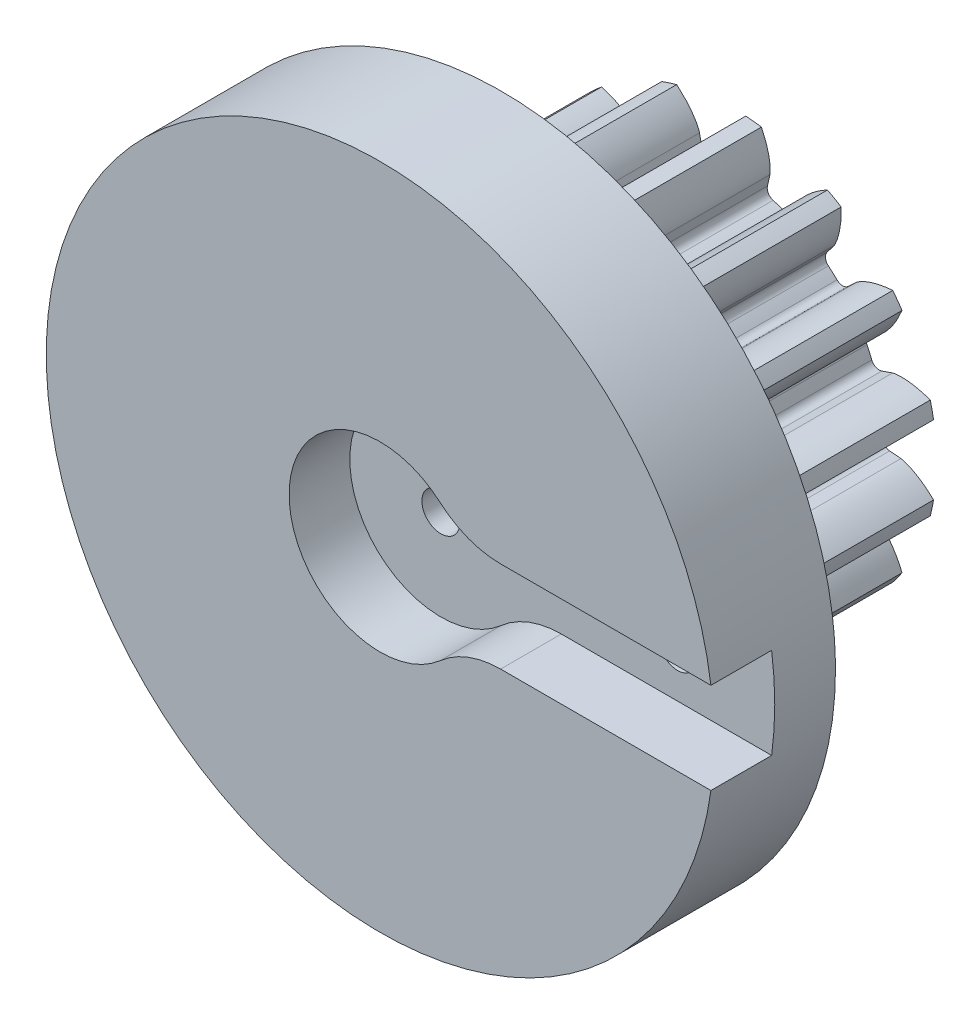
from build123d import *

# Parameters (mm, degrees)
SKETCH3_R                = 8.995833333
BOSS_EXTRUDE1_DEPTH      = 10.16
CUT_EXTRUDE1_DEPTH       = 17.281143532
FILLET1_R                = 0.355076163
CIRPATTERN1_COUNT        = 15
FILLET1_OF_CIRPATTERN1_R = 0.355076163
SCALE1_SCALE             = 1.9
SKETCH12_R               = 27.94
BOSS_EXTRUDE3_DEPTH      = 10.16
SKETCH13_R               = 5.08
CUT_EXTRUDE6_DEPTH       = 50.289093383
CUT_EXTRUDE7_DEPTH       = 5.08
SKETCH15_R               = 1.5875
CUT_EXTRUDE8_DEPTH       = 5.08
SKETCH16_R               = 2.74955
CUT_EXTRUDE9_DEPTH       = 3.81
SKETCH18_R               = 5.08
BOSS_EXTRUDE4_DEPTH      = 24.384
SKETCH19_R               = 2.794
CUT_EXTRUDE10_DEPTH      = 22.86
SKETCH20_R               = 1.5875
CUT_EXTRUDE11_DEPTH      = 46.649391906


with BuildPart() as part:
    # Sketch3 → Boss-Extrude1 (new body)
    with BuildSketch(Plane.XY):
        Circle(SKETCH3_R)
    extrude(amount=-BOSS_EXTRUDE1_DEPTH)

    # Sketch4 → Cut-Extrude1 (cut, symmetric)
    with BuildSketch(Plane.XY):
        with BuildLine():
            Line((6.587922, 0.593292844), (7.428746027, 0.669015489))
            add(Edge.make_bspline(
                [(7.428746027, 0.669015489), (7.431239529, 0.669275952), (7.438221543, 0.670116627), (7.45137303, 0.672140658), (7.47274968, 0.676058941), (7.499853291, 0.681954394), (7.534710401, 0.690607559), (7.575527841, 0.702125727), (7.620103171, 0.716165985), (7.668268726, 0.7329259), (7.716008275, 0.750953862), (7.763320815, 0.770148726), (7.810159557, 0.790358577), (7.866530888, 0.816118543), (7.933604431, 0.848781677), (8.011190656, 0.889523955), (8.098185635, 0.938742517), (8.185706836, 0.992089652), (8.27086582, 1.04719041), (8.355732614, 1.105822875), (8.437008174, 1.164648852), (8.520142822, 1.228735923), (8.59623198, 1.289414256), (8.679980615, 1.360650951), (8.747135157, 1.419094683), (8.815206291, 1.48214701), (8.84814287, 1.513228673), (8.864892817, 1.529278494)],
                knots=[0, 0, 0, 0, 0, 0.005376749, 0.015083688, 0.02853182, 0.04661014, 0.064854849, 0.092110525, 0.119476176, 0.146842496, 0.174208854, 0.201574956, 0.228941013, 0.256307345, 0.307035032, 0.361767352, 0.416499661, 0.471231937, 0.525964282, 0.580696616, 0.635428982, 0.690161387, 0.744893688, 0.799626082, 0.854358408, 0.909090915, 0.909090915, 0.909090915, 0.909090915, 0.909090915], degree=4))
            ThreePointArc((8.864892817, 1.529278494), (8.995833333, 0), (8.864892817, -1.529278494))
            add(Edge.make_bspline(
                [(7.428746027, -0.669015489), (7.431239529, -0.669275952), (7.438221543, -0.670116627), (7.45137303, -0.672140658), (7.47274968, -0.676058941), (7.499853291, -0.681954394), (7.534710401, -0.690607559), (7.575527841, -0.702125727), (7.620103171, -0.716165985), (7.668268726, -0.7329259), (7.716008275, -0.750953862), (7.763320815, -0.770148726), (7.810159557, -0.790358577), (7.866530888, -0.816118543), (7.933604431, -0.848781677), (8.011190656, -0.889523955), (8.098185635, -0.938742517), (8.185706836, -0.992089652), (8.27086582, -1.04719041), (8.355732614, -1.105822875), (8.437008174, -1.164648852), (8.520142822, -1.228735923), (8.59623198, -1.289414256), (8.679980615, -1.360650951), (8.747135157, -1.419094683), (8.815206291, -1.48214701), (8.84814287, -1.513228673), (8.864892817, -1.529278494)],
                knots=[0, 0, 0, 0, 0, 0.005376749, 0.015083688, 0.02853182, 0.04661014, 0.064854849, 0.092110525, 0.119476176, 0.146842496, 0.174208854, 0.201574956, 0.228941013, 0.256307345, 0.307035032, 0.361767352, 0.416499661, 0.471231937, 0.525964282, 0.580696616, 0.635428982, 0.690161387, 0.744893688, 0.799626082, 0.854358408, 0.909090915, 0.909090915, 0.909090915, 0.909090915, 0.909090915], degree=4))
            Line((7.428746027, -0.669015489), (6.587922, -0.593292844))
            ThreePointArc((6.587922, -0.593292844), (6.614583333, 0), (6.587922, 0.593292844))
        make_face()
    cut_extrude1 = extrude(amount=CUT_EXTRUDE1_DEPTH, both=True, mode=Mode.SUBTRACT)

    # Fillet1
    fillet1_edges = [part.edges().sort_by_distance(p)[0] for p in [
        (6.587922, -0.593292844, -5.08),
        (6.587922, 0.593292844, -5.08),
    ]]
    fillet(fillet1_edges, radius=FILLET1_R)

    # CirPattern1: Cut-Extrude1 ×15 about axis
    cirpattern1_axis = Axis((0, 0, 6.35), (0, 0, -1))
    for i in range(1, CIRPATTERN1_COUNT):
        add(cut_extrude1.rotate(cirpattern1_axis, i * 360 / CIRPATTERN1_COUNT), mode=Mode.SUBTRACT)

    # Fillet1 of CirPattern1
    fillet1_of_cirpattern1_edges = [part.edges().sort_by_distance(p)[0] for p in [
        (5.777052279, -3.221549262, -5.08),
        (6.259680158, -2.137549296, -5.08),
        (3.967277735, -5.292770545, -5.08),
        (4.849082749, -4.498789744, -5.08),
        (1.47152483, -6.448823718, -5.08),
        (2.600034881, -6.082148575, -5.08),
        (-1.278668086, -6.489816685, -5.08),
        (-0.098582639, -6.613848663, -5.08),
        (-3.807767675, -5.408661388, -5.08),
        (-2.780154325, -6.001954232, -5.08),
        (-5.678469639, -3.392299401, -5.08),
        (-4.981012072, -4.352267388, -5.08),
        (-6.567312616, -0.78937803, -5.08),
        (-6.32060758, -1.950033974, -5.08),
        (-6.32060758, 1.950033974, -5.08),
        (-6.567312616, 0.78937803, -5.08),
        (-4.981012072, 4.352267388, -5.08),
        (-5.678469639, 3.392299401, -5.08),
        (-2.780154325, 6.001954232, -5.08),
        (-3.807767675, 5.408661388, -5.08),
        (-0.098582639, 6.613848663, -5.08),
        (-1.278668086, 6.489816685, -5.08),
        (2.600034881, 6.082148575, -5.08),
        (1.47152483, 6.448823718, -5.08),
        (4.849082749, 4.498789744, -5.08),
        (3.967277735, 5.292770545, -5.08),
        (6.259680158, 2.137549296, -5.08),
        (5.777052279, 3.221549262, -5.08),
    ]]
    fillet(fillet1_of_cirpattern1_edges, radius=FILLET1_OF_CIRPATTERN1_R)


with BuildPart() as part_1:
    # Scale1: scaled about (0, 0, -5.079999622)
    add(part.part.scale(SCALE1_SCALE).moved(Location((0, 0, 4.57199966))))


with BuildPart() as boss_extrude3_tool:
    # Sketch12 → Boss-Extrude3 (new body)
    with BuildSketch(Plane.XY.offset(4.572003283)):
        Circle(SKETCH12_R)
    extrude(amount=BOSS_EXTRUDE3_DEPTH)


with BuildPart() as part_2:
    add(part_1.part)


with BuildPart() as part_3:
    # Boss-Extrude3: joined with boss_extrude3_tool
    add(part_2.part.fuse(boss_extrude3_tool.part, tol=0.00001))

    # Sketch13 → Cut-Extrude6 (cut, through all)
    with BuildSketch(Plane.XY.offset(14.732003283)):
        Circle(SKETCH13_R)
    extrude(amount=-CUT_EXTRUDE6_DEPTH, mode=Mode.SUBTRACT)

    # Sketch14 → Cut-Extrude7 (cut)
    with BuildSketch(Plane.XY.offset(14.732003283)):
        with BuildLine():
            Line((10.080312495, 3.81), (29.344687406, 3.81))
            Line((29.344687406, 3.81), (29.344687406, -3.81))
            Line((29.344687406, -3.81), (10.080312495, -3.81))
            ThreePointArc((10.080312495, -3.81), (7.386235659, -4.302142678), (5.040156248, -5.715))
            ThreePointArc((5.040156248, -5.715), (-7.62, 0), (5.040156248, 5.715))
            ThreePointArc((5.040156248, 5.715), (7.386235659, 4.302142678), (10.080312495, 3.81))
        make_face()
    extrude(amount=-CUT_EXTRUDE7_DEPTH, mode=Mode.SUBTRACT)

    # Sketch15 → Cut-Extrude8 (cut)
    with BuildSketch(Plane.XY.offset(9.652003283)):
        with Locations((19.812, 0)):
            Circle(SKETCH15_R)
    extrude(amount=-CUT_EXTRUDE8_DEPTH, mode=Mode.SUBTRACT)

    # Sketch16 → Cut-Extrude9 (cut)
    with BuildSketch(Plane(origin=(0, 0, 4.572003283), x_dir=(-1, 0, 0), z_dir=(0, 0, -1))):
        with Locations((-19.812, 0)):
            Circle(SKETCH16_R)
    extrude(amount=-CUT_EXTRUDE9_DEPTH, mode=Mode.SUBTRACT)

    # Sketch18 → Boss-Extrude4 (add)
    with BuildSketch(Plane(origin=(0, 0, -14.731996717), x_dir=(-1, 0, 0), z_dir=(0, 0, -1))):
        Circle(SKETCH18_R)
    extrude(amount=-BOSS_EXTRUDE4_DEPTH)

    # Sketch19 → Cut-Extrude10 (cut)
    with BuildSketch(Plane(origin=(0, 0, -14.731996717), x_dir=(-1, 0, 0), z_dir=(0, 0, -1))):
        Circle(SKETCH19_R)
    extrude(amount=-CUT_EXTRUDE10_DEPTH, mode=Mode.SUBTRACT)

    # Sketch20 → Cut-Extrude11 (cut, through all)
    with BuildSketch(Plane(origin=(0, 0, 8.128003283), x_dir=(-1, 0, 0), z_dir=(0, 0, -1))):
        Circle(SKETCH20_R)
    extrude(amount=-CUT_EXTRUDE11_DEPTH, mode=Mode.SUBTRACT)


solid = part_3.part
